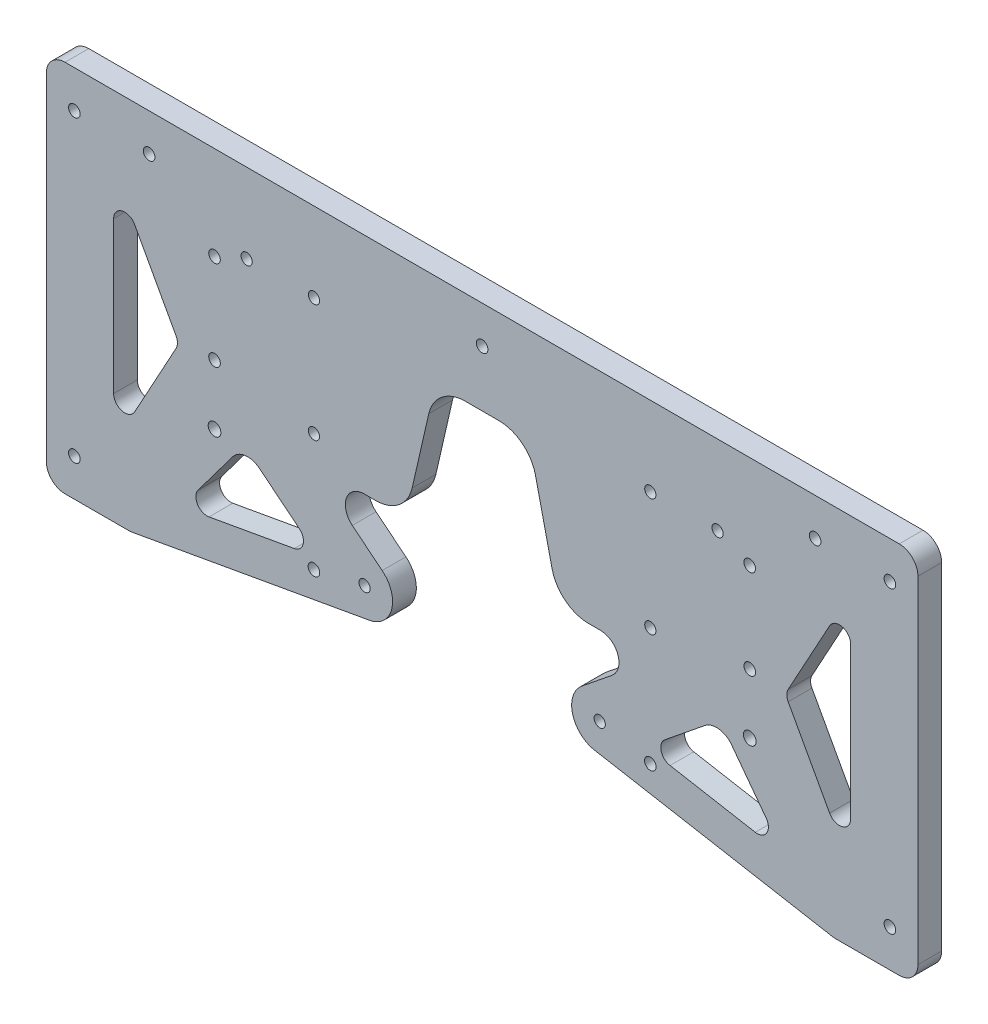
from build123d import *

# Parameters (mm, degrees)
SKETCH1_W           = 233.2
SKETCH1_H           = 100
SKETCH1_R           = 1.55
BOSS_EXTRUDE1_DEPTH = 6.35
FILLET1_R           = 5
SKETCH2_R           = 1.55
CUT_EXTRUDE1_DEPTH  = 6.35
SKETCH3_W           = 10
SKETCH3_H           = 12.7
BOSS_EXTRUDE2_DEPTH = 6.35
FILLET2_R           = 5
FILLET3_R           = 10
FILLET4_R           = 2
FILLET5_R           = 20
FILLET6_R           = 5
CUT_EXTRUDE2_DEPTH  = 10
SKETCH5_W           = 120
SKETCH5_H           = 40
CUT_EXTRUDE4_DEPTH  = 10
SKETCH6_R           = 1.5
CUT_EXTRUDE5_DEPTH  = 10
FILLET7_R           = 10
SKETCH7_W           = 25
SKETCH7_H           = 35
CUT_EXTRUDE6_DEPTH  = 10
FILLET9_R           = 10
SKETCH8_R           = 1.5
CUT_EXTRUDE7_DEPTH  = 10
BOSS_EXTRUDE3_DEPTH = 6.35
FILLET10_R          = 5
BOSS_EXTRUDE4_DEPTH = 6.35
FILLET11_R          = 3
FILLET12_R          = 3
CUT_EXTRUDE8_DEPTH  = 10
FILLET13_R          = 3
CUT_EXTRUDE9_DEPTH  = 10
SKETCH13_R          = 1.55
CUT_EXTRUDE10_DEPTH = 10


with BuildPart() as part:
    # Sketch1 → Boss-Extrude1 (new body)
    with BuildSketch(Plane.XY):
        with Locations((116.6, -50)):
            Rectangle(SKETCH1_W, SKETCH1_H)
        with Locations((7.5, -10)):
            Circle(SKETCH1_R, mode=Mode.SUBTRACT)
        with Locations((225.7, -10)):
            Circle(SKETCH1_R, mode=Mode.SUBTRACT)
        with Locations((7.5, -90)):
            Circle(SKETCH1_R, mode=Mode.SUBTRACT)
        with Locations((225.7, -90)):
            Circle(SKETCH1_R, mode=Mode.SUBTRACT)
        with Locations((27.5, -10)):
            Circle(SKETCH1_R, mode=Mode.SUBTRACT)
        with Locations((205.7, -10)):
            Circle(SKETCH1_R, mode=Mode.SUBTRACT)
        with Locations((116.6, -10)):
            Circle(SKETCH1_R, mode=Mode.SUBTRACT)
    extrude(amount=BOSS_EXTRUDE1_DEPTH)

    # Fillet1
    fillet1_edges = [part.edges().sort_by_distance(p)[0] for p in [
        (233.2, -100, 3.175),
        (0, -100, 3.175),
        (0, 0, 3.175),
        (233.2, 0, 3.175),
    ]]
    fillet(fillet1_edges, radius=FILLET1_R)

    # Sketch2 → Cut-Extrude1 (cut)
    with BuildSketch(Plane.XY.offset(6.35)):
        with Locations((45, -25)):
            Circle(SKETCH2_R)
        with Locations((45, -49)):
            Circle(SKETCH2_R)
        with Locations(Location((188.2, -49, 0), (0, 0, 180))):
            Circle(SKETCH2_R)
        with Locations(Location((188.2, -25, 0), (0, 0, 180))):
            Circle(SKETCH2_R)
    extrude(amount=-CUT_EXTRUDE1_DEPTH, mode=Mode.SUBTRACT)

    # Sketch3 → Boss-Extrude2 (add)
    with BuildSketch(Plane.XY.offset(6.35)):
        with Locations((125.723568259, 6.35)):
            Rectangle(SKETCH3_W, SKETCH3_H)
        Polygon((120.723568259, 16.7), (120.723568259, 12.7), (130.723568259, 12.7), (130.723568259, 24.7), (85.723568259, 24.7), (85.723568259, 12.7), (95.723568259, 12.7), (95.723568259, 16.7), align=None)
        Polygon((130.723568259, 12.7), (130.723568259, 0), (152.313568259, 0), (130.723568259, 24.7), align=None)
    extrude(amount=-BOSS_EXTRUDE2_DEPTH)

    # Fillet2
    fillet2_edges = [part.edges().sort_by_distance(p)[0] for p in [
        (85.723568259, 12.7, 3.175),
    ]]
    fillet(fillet2_edges, radius=FILLET2_R)

    # Fillet3
    fillet3_edges = [part.edges().sort_by_distance(p)[0] for p in [
        (120.723568259, 0, 3.175),
    ]]
    fillet(fillet3_edges, radius=FILLET3_R)

    # Fillet4
    fillet4_edges = [part.edges().sort_by_distance(p)[0] for p in [
        (85.723568259, 24.7, 3.175),
    ]]
    fillet(fillet4_edges, radius=FILLET4_R)

    # Fillet5
    fillet5_edges = [part.edges().sort_by_distance(p)[0] for p in [
        (130.723568259, 24.7, 3.175),
        (152.313568259, 0, 3.175),
    ]]
    fillet(fillet5_edges, radius=FILLET5_R)

    # Fillet6
    fillet6_edges = [part.edges().sort_by_distance(p)[0] for p in [
        (120.723568259, 16.7, 3.175),
    ]]
    fillet(fillet6_edges, radius=FILLET6_R)

    # Sketch4 → Cut-Extrude2 (cut)
    with BuildSketch(Plane(origin=(0, 0, 0), x_dir=(-1, 0, 0), z_dir=(0, 0, -1))):
        with BuildLine():
            Line((-110.723568259, 0), (-161.395157905, 0))
            ThreePointArc((-161.395157905, 0), (-153.126132222, 1.789475179), (-146.33682816, 6.837678575))
            Line((-146.33682816, 6.837678575), (-136.700308357, 17.862321425))
            ThreePointArc((-136.700308357, 17.862321425), (-129.911004296, 22.910524821), (-121.641978613, 24.7))
            Line((-121.641978613, 24.7), (-87.723568259, 24.7))
            ThreePointArc((-87.723568259, 24.7), (-86.309354696, 24.114213562), (-85.723568259, 22.7))
            Line((-85.723568259, 22.7), (-85.723568259, 17.7))
            ThreePointArc((-85.723568259, 17.7), (-87.188034353, 14.164466094), (-90.723568259, 12.7))
            Line((-90.723568259, 12.7), (-95.723568259, 12.7))
            Line((-95.723568259, 12.7), (-95.723568259, 16.7))
            Line((-95.723568259, 16.7), (-115.723568259, 16.7))
            ThreePointArc((-115.723568259, 16.7), (-119.259102165, 15.235533906), (-120.723568259, 11.7))
            Line((-120.723568259, 11.7), (-120.723568259, 10))
            ThreePointArc((-120.723568259, 10), (-117.794636071, 2.928932188), (-110.723568259, 0))
        make_face()
    extrude(amount=-CUT_EXTRUDE2_DEPTH, mode=Mode.SUBTRACT)

    # Sketch5 → Cut-Extrude4 (cut)
    with BuildSketch(Plane.XY.offset(6.35)):
        Polygon((56.6, -100), (56.6, -60), (26.6, -100), align=None)
        with Locations((116.6, -80)):
            Rectangle(SKETCH5_W, SKETCH5_H)
        Polygon((206.6, -100), (176.6, -60), (176.6, -100), align=None)
    extrude(amount=-CUT_EXTRUDE4_DEPTH, mode=Mode.SUBTRACT)

    # Sketch6 → Cut-Extrude5 (cut)
    with BuildSketch(Plane.XY.offset(6.35)):
        with Locations((71.6, -21.25)):
            Circle(SKETCH6_R)
        with Locations((161.6, -21.25)):
            Circle(SKETCH6_R)
        with Locations((161.6, -52.75)):
            Circle(SKETCH6_R)
        with Locations((71.6, -52.75)):
            Circle(SKETCH6_R)
    extrude(amount=-CUT_EXTRUDE5_DEPTH, mode=Mode.SUBTRACT)

    # Fillet7
    fillet7_edges = [part.edges().sort_by_distance(p)[0] for p in [
        (206.6, -100, 3.175),
        (26.6, -100, 3.175),
        (56.6, -60, 3.175),
        (176.6, -60, 3.175),
    ]]
    fillet(fillet7_edges, radius=FILLET7_R)

    # Sketch7 → Cut-Extrude6 (cut)
    with BuildSketch(Plane.XY.offset(6.35)):
        Polygon((96.1, -60), (104.1, -60), (104.1, -25), align=None)
        Polygon((129.1, -25), (129.1, -60), (137.1, -60), align=None)
        with Locations((116.6, -42.5)):
            Rectangle(SKETCH7_W, SKETCH7_H)
    extrude(amount=-CUT_EXTRUDE6_DEPTH, mode=Mode.SUBTRACT)

    # Fillet9
    fillet9_edges = [part.edges().sort_by_distance(p)[0] for p in [
        (137.1, -60, 3.175),
        (96.1, -60, 3.175),
        (104.1, -25, 3.175),
        (129.1, -25, 3.175),
    ]]
    fillet(fillet9_edges, radius=FILLET9_R)

    # Sketch8 → Cut-Extrude7 (cut)
    with BuildSketch(Plane.XY.offset(6.35)):
        with Locations((53.6, -21.25)):
            Circle(SKETCH8_R)
        with Locations((179.6, -21.25)):
            Circle(SKETCH8_R)
    extrude(amount=-CUT_EXTRUDE7_DEPTH, mode=Mode.SUBTRACT)

    # Sketch9 → Boss-Extrude3 (add)
    with BuildSketch(Plane.XY.offset(6.35)):
        with BuildLine():
            Line((53.6, -64), (52.97582451, -64.832233986))
            Line((52.97582451, -64.832233986), (80.428117061, -87.022837132))
            ThreePointArc((80.428117061, -87.022837132), (90.975638571, -85.904897064), (89.857698503, -75.357375554))
            Line((89.857698503, -75.357375554), (70.858883385, -60))
            Line((70.858883385, -60), (61.6, -60))
            ThreePointArc((61.6, -60), (57.127864045, -61.05572809), (53.6, -64))
        make_face()
        with BuildLine():
            ThreePointArc((83.976361625, -80.247148199), (85.642998156, -79.775924736), (86.642907782, -81.190106343))
            ThreePointArc((86.642907782, -81.190106343), (84.642817409, -82.60428795), (83.976361625, -80.247148199))
        make_face(mode=Mode.SUBTRACT)
    boss_extrude3 = extrude(amount=-BOSS_EXTRUDE3_DEPTH)

    # Mirror1: Boss-Extrude3 across plane
    add(boss_extrude3.mirror(Plane.ZY.offset(-116.6)))

    # Fillet10
    fillet10_edges = [part.edges().sort_by_distance(p)[0] for p in [
        (52.97582451, -64.832233986, 3.175),
        (70.858883385, -60, 3.175),
        (180.22417549, -64.832233986, 3.175),
        (162.341116615, -60, 3.175),
    ]]
    fillet(fillet10_edges, radius=FILLET10_R)

    # Sketch10 → Boss-Extrude4 (add)
    with BuildSketch(Plane.XY.offset(6.35)):
        with BuildLine():
            ThreePointArc((29.6, -96), (26.844092638, -98.514663376), (23.358283237, -99.844208453))
            Line((23.358283237, -99.844208453), (86.46162021, -88.573262682))
            ThreePointArc((86.46162021, -88.573262682), (83.276282006, -88.454107183), (80.428117061, -87.022837132))
            Line((80.428117061, -87.022837132), (72.798322589, -80.855419933))
            Line((72.798322589, -80.855419933), (36.033483436, -87.422022085))
            Line((36.033483436, -87.422022085), (29.6, -96))
        make_face()
    boss_extrude4 = extrude(amount=-BOSS_EXTRUDE4_DEPTH)

    # Fillet11
    fillet11_edges = [part.edges().sort_by_distance(p)[0] for p in [
        (36.033483436, -87.422022085, 3.175),
        (72.798322589, -80.855419933, 3.175),
    ]]
    fillet(fillet11_edges, radius=FILLET11_R)

    # Mirror3: Boss-Extrude4 across plane
    add(boss_extrude4.mirror(Plane.ZY.offset(-116.6)))

    # Fillet12
    fillet12_edges = [part.edges().sort_by_distance(p)[0] for p in [
        (197.166516564, -87.422022085, 3.175),
        (160.401677411, -80.855419933, 3.175),
    ]]
    fillet(fillet12_edges, radius=FILLET12_R)

    # Sketch11 → Cut-Extrude8 (cut)
    with BuildSketch(Plane.XY.offset(6.35)):
        Polygon((35.5, -50), (18, -82), (18, -18), align=None)
        Polygon((215.2, -18), (215.2, -82), (197.7, -50), align=None)
    extrude(amount=-CUT_EXTRUDE8_DEPTH, mode=Mode.SUBTRACT)

    # Fillet13
    fillet13_edges = [part.edges().sort_by_distance(p)[0] for p in [
        (35.5, -50, 3.175),
        (18, -82, 3.175),
        (18, -18, 3.175),
        (215.2, -18, 3.175),
        (215.2, -82, 3.175),
        (197.7, -50, 3.175),
    ]]
    fillet(fillet13_edges, radius=FILLET13_R)

    # Sketch12 → Cut-Extrude9 (cut)
    with BuildSketch(Plane.XY.offset(6.35)):
        with BuildLine():
            ThreePointArc((186.5, -65), (188.2, -66.7), (189.9, -65))
            ThreePointArc((189.9, -65), (188.2, -63.3), (186.5, -65))
        make_face()
        with BuildLine():
            ThreePointArc((43.3, -65), (45, -66.7), (46.7, -65))
            ThreePointArc((46.7, -65), (45, -63.3), (43.3, -65))
        make_face()
    extrude(amount=-CUT_EXTRUDE9_DEPTH, mode=Mode.SUBTRACT)

    # Sketch13 → Cut-Extrude10 (cut)
    with BuildSketch(Plane.XY.offset(6.35)):
        with Locations((161.599999999, -84.25)):
            Circle(SKETCH13_R)
        with Locations((71.6, -84.25)):
            Circle(SKETCH13_R)
    extrude(amount=-CUT_EXTRUDE10_DEPTH, mode=Mode.SUBTRACT)


solid = part.part
